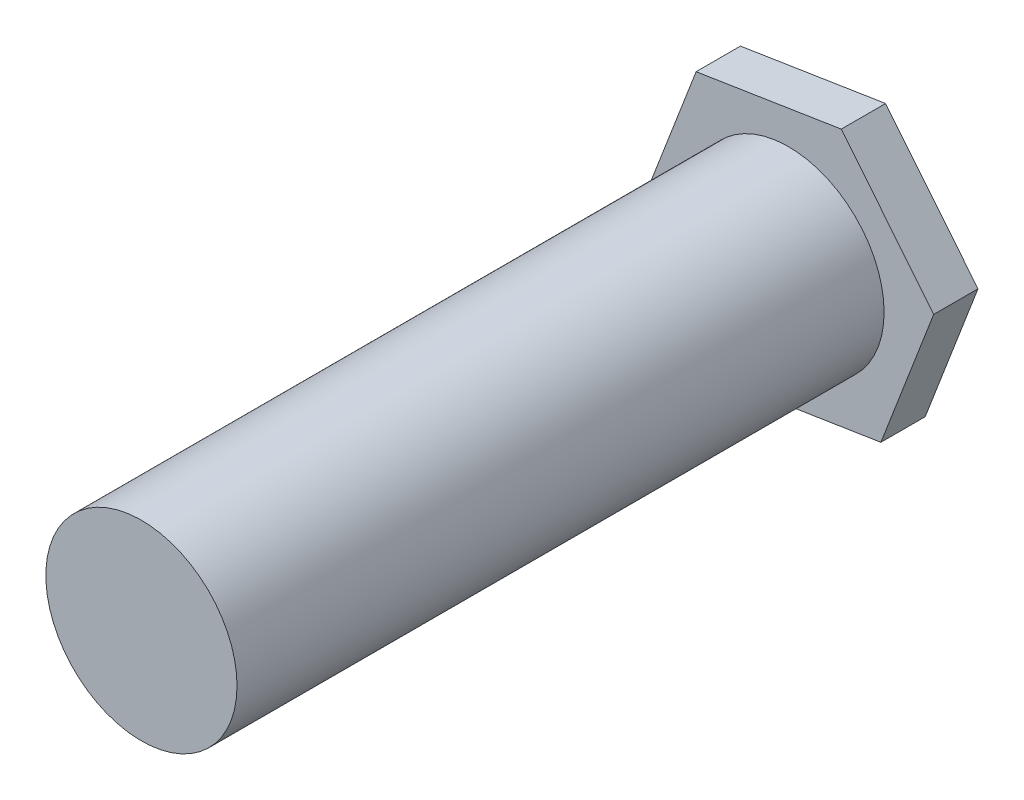
from build123d import *

# Parameters (mm, degrees)
SKETCH1_R                = 2.73924182
BOSS_EXTRUDE1_DEPTH      = 18.034
BOSS_EXTRUDE1_DEPTH_BACK = 0.508
BOSS_EXTRUDE2_DEPTH      = 1.27


with BuildPart() as part:
    # Sketch1 → Boss-Extrude1 (new body, two sides)
    with BuildSketch(Plane.XY) as boss_extrude1_sk:
        Circle(SKETCH1_R)
    extrude(amount=BOSS_EXTRUDE1_DEPTH)
    extrude(boss_extrude1_sk.sketch, amount=-BOSS_EXTRUDE1_DEPTH_BACK)

    # Sketch2 → Boss-Extrude2 (add)
    with BuildSketch(Plane(origin=(0, 0, -0.508), x_dir=(-1, 0, 0), z_dir=(0, 0, -1))):
        Polygon((2.647524392, 3.275316604), (-1.512745189, 3.930481683), (-4.160269581, 0.655165078), (-2.647524392, -3.275316604), (1.512745189, -3.930481683), (4.160269581, -0.655165078), align=None)
    extrude(amount=BOSS_EXTRUDE2_DEPTH)


solid = part.part
